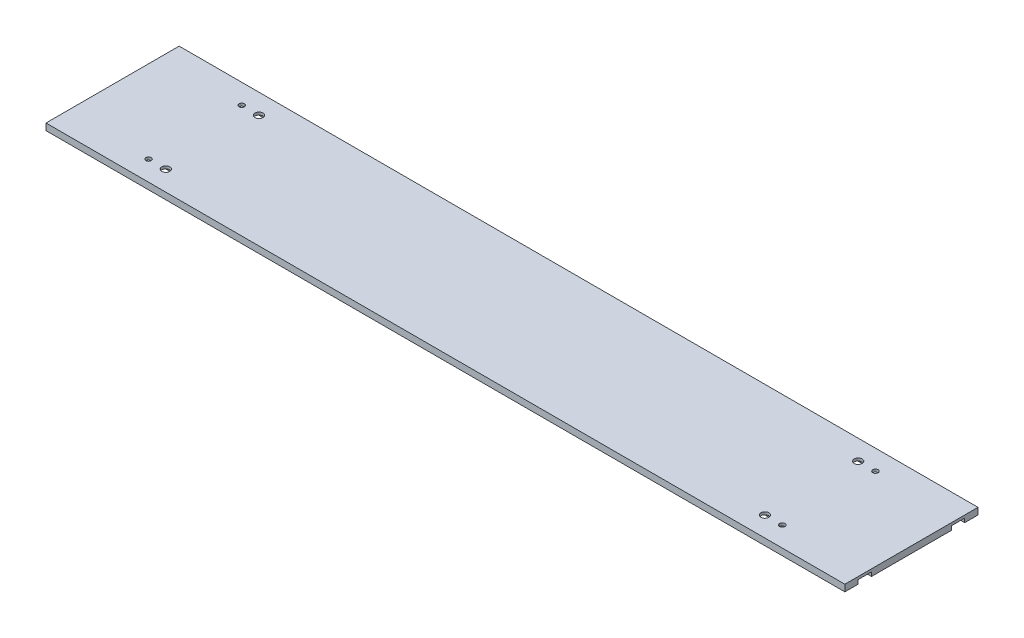
from build123d import *

# Parameters (mm, degrees)
SKETCH1_W           = 600
SKETCH1_H           = 5
BOSS_EXTRUDE1_DEPTH = 100
SKETCH6_R           = 2
CUT_EXTRUDE2_DEPTH  = 6
SKETCH7_R           = 3
CUT_EXTRUDE3_DEPTH  = 6
SKETCH8_W           = 600
SKETCH8_H           = 10
CUT_EXTRUDE5_DEPTH  = 3


with BuildPart() as part:
    # Sketch1 → Boss-Extrude1 (new body)
    with BuildSketch(Plane.XY):
        with Locations((300, 2.5)):
            Rectangle(SKETCH1_W, SKETCH1_H)
    extrude(amount=-BOSS_EXTRUDE1_DEPTH)

    # Sketch6 → Cut-Extrude2 (cut, through all)
    with BuildSketch(Plane(origin=(0, 5, 0), x_dir=(1, 0, 0), z_dir=(0, 1, 0))):
        with Locations((62, 85)):
            Circle(SKETCH6_R)
        with Locations((62, 15)):
            Circle(SKETCH6_R)
        with Locations((538, 85)):
            Circle(SKETCH6_R)
        with Locations((538, 15)):
            Circle(SKETCH6_R)
    extrude(amount=-CUT_EXTRUDE2_DEPTH, mode=Mode.SUBTRACT)

    # Sketch7 → Cut-Extrude3 (cut, through all)
    with BuildSketch(Plane(origin=(0, 5, 0), x_dir=(1, 0, 0), z_dir=(0, 1, 0))):
        with Locations((75, 85)):
            Circle(SKETCH7_R)
        with Locations((75, 15)):
            Circle(SKETCH7_R)
        with Locations((525, 85)):
            Circle(SKETCH7_R)
        with Locations((525, 15)):
            Circle(SKETCH7_R)
    extrude(amount=-CUT_EXTRUDE3_DEPTH, mode=Mode.SUBTRACT)

    # Sketch8 → Cut-Extrude5 (cut)
    with BuildSketch(Plane.XZ):
        with Locations((300, -15)):
            Rectangle(SKETCH8_W, SKETCH8_H)
        with Locations((300, -85)):
            Rectangle(SKETCH8_W, SKETCH8_H)
    extrude(amount=-CUT_EXTRUDE5_DEPTH, mode=Mode.SUBTRACT)


solid = part.part
